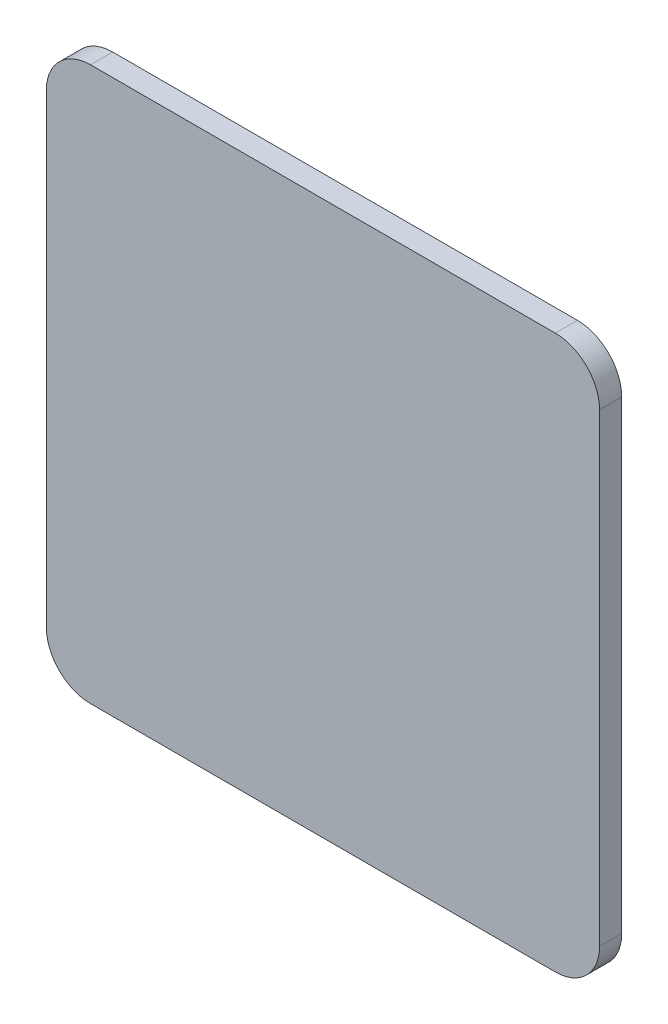
from build123d import *

# Parameters (mm, degrees)
BOSS_EXTRUDE1_DEPTH = 5.08


with BuildPart() as part:
    # Sketch1 → Boss-Extrude1 (new body)
    with BuildSketch(Plane.XY):
        with BuildLine():
            Line((53.34, 63.5), (-53.34, 63.5))
            ThreePointArc((-53.34, 63.5), (-60.524204897, 60.524204897), (-63.5, 53.34))
            Line((-63.5, 53.34), (-63.5, -53.34))
            ThreePointArc((-63.5, -53.34), (-60.524204897, -60.524204897), (-53.34, -63.5))
            Line((-53.34, -63.5), (53.34, -63.5))
            ThreePointArc((53.34, -63.5), (60.524204897, -60.524204897), (63.5, -53.34))
            Line((63.5, -53.34), (63.5, 53.34))
            ThreePointArc((63.5, 53.34), (60.524204897, 60.524204897), (53.34, 63.5))
        make_face()
        with BuildLine():
            ThreePointArc((58.42, 53.34), (56.932102448, 56.932102448), (53.34, 58.42))
            Line((53.34, 58.42), (-53.34, 58.42))
            ThreePointArc((-53.34, 58.42), (-56.932102448, 56.932102448), (-58.42, 53.34))
            Line((-58.42, 53.34), (-58.42, -53.34))
            ThreePointArc((-58.42, -53.34), (-56.932102448, -56.932102448), (-53.34, -58.42))
            Line((-53.34, -58.42), (53.34, -58.42))
            ThreePointArc((53.34, -58.42), (56.932102448, -56.932102448), (58.42, -53.34))
            Line((58.42, -53.34), (58.42, 53.34))
        make_face(mode=Mode.SUBTRACT)
        with BuildLine():
            Line((58.42, 53.34), (58.42, -53.34))
            ThreePointArc((58.42, -53.34), (56.932102448, -56.932102448), (53.34, -58.42))
            Line((53.34, -58.42), (-53.34, -58.42))
            ThreePointArc((-53.34, -58.42), (-56.932102448, -56.932102448), (-58.42, -53.34))
            Line((-58.42, -53.34), (-58.42, 53.34))
            ThreePointArc((-58.42, 53.34), (-56.932102448, 56.932102448), (-53.34, 58.42))
            Line((-53.34, 58.42), (53.34, 58.42))
            ThreePointArc((53.34, 58.42), (56.932102448, 56.932102448), (58.42, 53.34))
        make_face()
    extrude(amount=BOSS_EXTRUDE1_DEPTH)


solid = part.part
